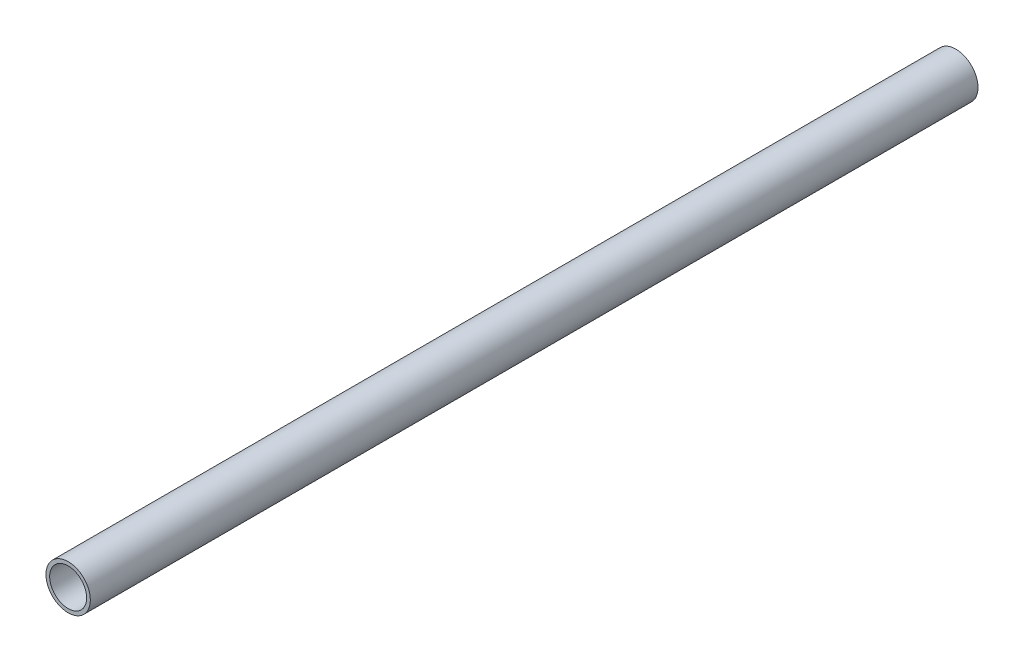
from build123d import *

# Parameters (mm, degrees)
SKETCH1_R           = 12
SKETCH1_R_2         = 10
BOSS_EXTRUDE1_DEPTH = 480


with BuildPart() as part:
    # Sketch1 → Boss-Extrude1 (new body)
    with BuildSketch(Plane.XY):
        Circle(SKETCH1_R)
        Circle(SKETCH1_R_2, mode=Mode.SUBTRACT)
    extrude(amount=BOSS_EXTRUDE1_DEPTH)


solid = part.part
